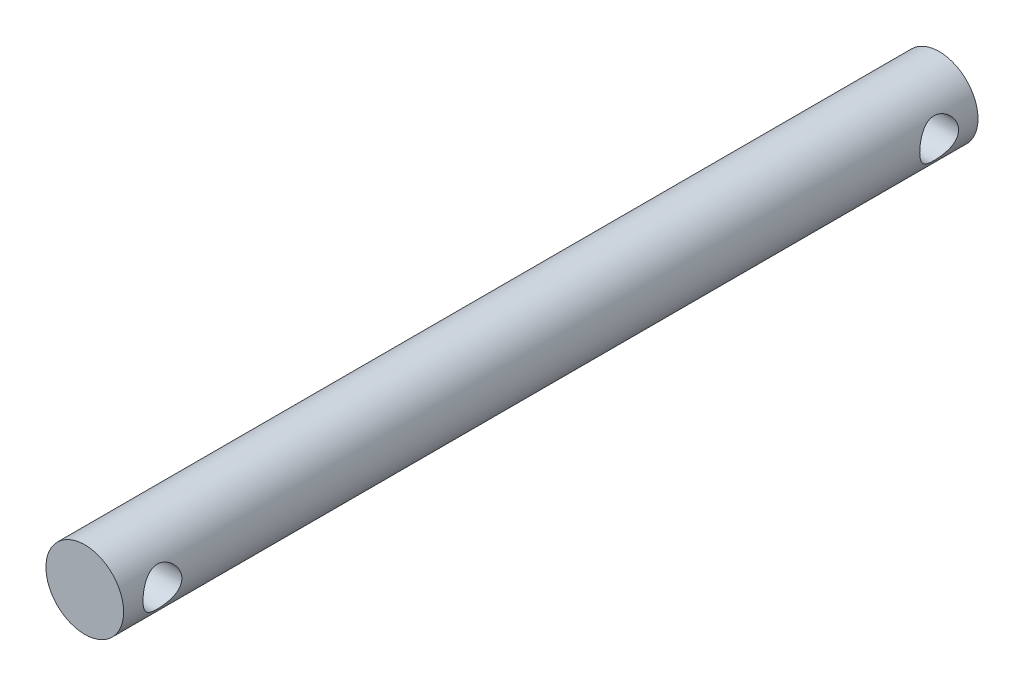
from build123d import *

# Parameters (mm, degrees)
SKETCH_1_R          = 3
EXTRUDE_1_DEPTH     = 33
SKETCH_2_R          = 1.5
CUT_EXTRUDE_1_DEPTH = 33


with BuildPart() as part:
    # 草圖1 → 填料-伸長1 (new body, symmetric)
    with BuildSketch(Plane.XY):
        Circle(SKETCH_1_R)
    extrude(amount=EXTRUDE_1_DEPTH, both=True)

    # 草圖2 → 除料-伸長1 (cut, symmetric)
    with BuildSketch(Plane(origin=(0, 0, 0), x_dir=(0, 0, -1), z_dir=(1, 0, 0))):
        with Locations((30, 0)):
            Circle(SKETCH_2_R)
        with Locations((-30, 0)):
            Circle(SKETCH_2_R)
    extrude(amount=CUT_EXTRUDE_1_DEPTH, both=True, mode=Mode.SUBTRACT)


solid = part.part
